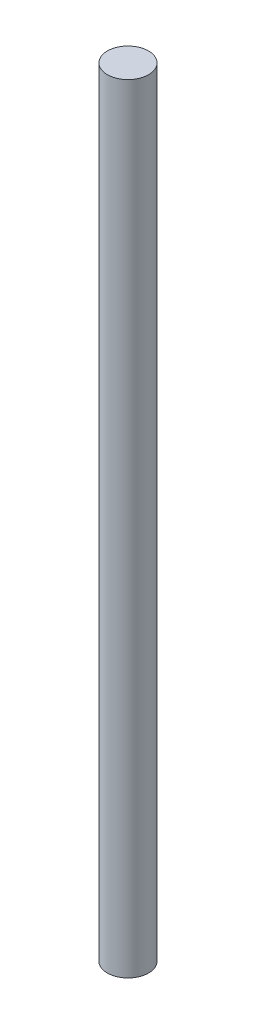
from build123d import *

# Parameters (mm, degrees)
SKETCH1_R           = 6.35
BOSS_EXTRUDE1_DEPTH = 120


with BuildPart() as part:
    # Sketch1 → Boss-Extrude1 (new body, symmetric)
    with BuildSketch(Plane(origin=(0, 0, 0), x_dir=(1, 0, 0), z_dir=(0, 1, 0))):
        Circle(SKETCH1_R)
    extrude(amount=BOSS_EXTRUDE1_DEPTH, both=True)


solid = part.part
